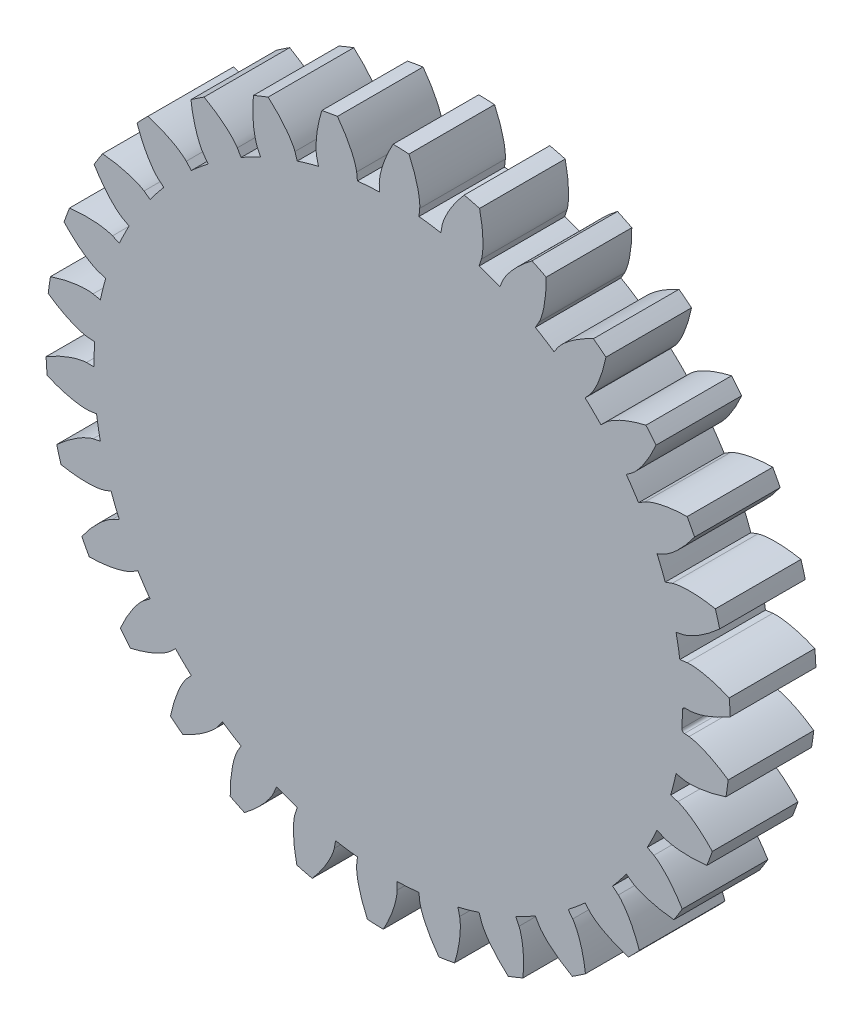
from build123d import *

# Parameters (mm, degrees)
SKETCH1_R           = 101.6
BOSS_EXTRUDE1_DEPTH = 25.4
CUT_EXTRUDE1_START  = -26.4
CUT_EXTRUDE1_DEPTH  = 27.4
FILLET1_R           = 0.846666582
CIRPATTERN14_COUNT  = 30


with BuildPart() as part:
    # Sketch1 → Boss-Extrude1 (new body)
    with BuildSketch(Plane.XY):
        Circle(SKETCH1_R)
    extrude(amount=BOSS_EXTRUDE1_DEPTH)

    # Sketch2 → Cut-Extrude1 (cut)
    with BuildSketch(Plane.XY.offset(25.4).offset(CUT_EXTRUDE1_START)):
        with BuildLine():
            Line((89.535, 0), (87.3125, 0))
            ThreePointArc((87.3125, 0), (87.251035108, -3.275595946), (87.066726971, -6.546580086))
            Line((87.066726971, -6.546580086), (89.28207872, -6.713153221))
            add(Edge.make_bspline(
                [(89.28207872, -6.713153221), (89.347981738, -6.719504015), (89.532356075, -6.74163053), (89.878865306, -6.80045399), (90.440132452, -6.920438435), (91.148215647, -7.108293037), (92.053640139, -7.390987754), (93.105965512, -7.774602293), (94.245607882, -8.248854973), (95.770160558, -8.963338492), (97.256955621, -9.757138616), (98.705933441, -10.617554773), (99.889296193, -11.387864793), (100.499115209, -11.803533802), (100.827967533, -12.033120003), (100.880506398, -12.069939061)],
                knots=[0, 0, 0, 0, 0, 0.005376748, 0.015083688, 0.02853182, 0.046610139, 0.064854849, 0.092110525, 0.119476175, 0.146842495, 0.201574955, 0.228941013, 0.256307345, 0.261518574, 0.261518574, 0.261518574, 0.261518574, 0.261518574], degree=4))
            ThreePointArc((100.880506398, -12.069939061), (101.419967092, -6.045682343), (101.6, 0))
            ThreePointArc((101.6, 0), (101.575363504, 2.237303943), (101.501465966, 4.473522859))
            add(Edge.make_bspline(
                [(89.535, 0), (89.601193491, 0.001400739), (89.786706717, 0.009666451), (90.13664656, 0.042391861), (90.705319373, 0.120034045), (91.425475953, 0.254368189), (92.349518307, 0.468507261), (93.42760249, 0.772288922), (94.599542233, 1.159919641), (96.173291899, 1.758300416), (97.715325972, 2.438601169), (99.224634468, 3.188161406), (100.462242333, 3.867699402), (101.101375389, 4.236511879), (101.446403766, 4.4407902), (101.501465966, 4.473522859)],
                knots=[0, 0, 0, 0, 0, 0.005376748, 0.015083688, 0.02853182, 0.046610139, 0.064854849, 0.092110525, 0.119476175, 0.146842495, 0.201574955, 0.228941013, 0.256307345, 0.261510527, 0.261510527, 0.261510527, 0.261510527, 0.261510527], degree=4))
        make_face()
    cut_extrude1 = extrude(amount=CUT_EXTRUDE1_DEPTH, mode=Mode.SUBTRACT)

    # Fillet1
    fillet1_edges = [part.edges().sort_by_distance(p)[0] for p in [
        (87.3125, 0, 12.7),
        (87.066726971, -6.546580086, 12.7),
    ]]
    fillet(fillet1_edges, radius=FILLET1_R)

    # CirPattern14: Cut-Extrude1 ×30 about axis
    cirpattern14_axis = Axis((0, 0, 25.4), (0, 0, -1))
    for i in range(1, CIRPATTERN14_COUNT):
        add(cut_extrude1.rotate(cirpattern14_axis, i * 360 / CIRPATTERN14_COUNT), mode=Mode.SUBTRACT)


solid = part.part
